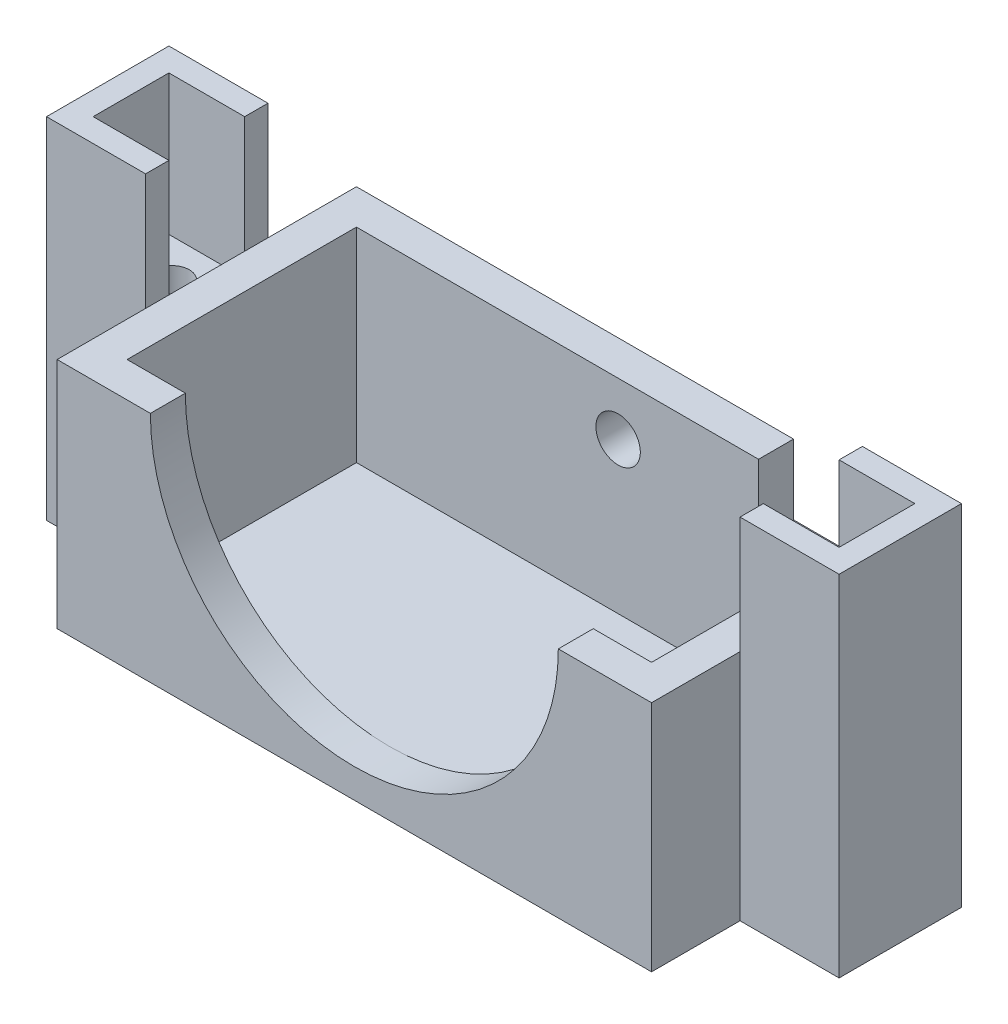
from build123d import *

# Parameters (mm, degrees)
SKETCH1_W           = 51
SKETCH1_H           = 25.68
BOSS_EXTRUDE1_DEPTH = 20
SKETCH2_W           = 45
SKETCH2_H           = 19.68
CUT_EXTRUDE1_DEPTH  = 17.5
CUT_EXTRUDE5_DEPTH  = 3
SKETCH10_R          = 1.905435321
SKETCH10_W          = 10
SKETCH10_H          = 6
CUT_EXTRUDE6_DEPTH  = 3
SKETCH11_W          = 6.5
SKETCH11_H          = 6.5
SKETCH11_R          = 1.5
BOSS_EXTRUDE4_DEPTH = 18
BOSS_EXTRUDE5_DEPTH = 30


with BuildPart() as part:
    # Sketch1 → Boss-Extrude1 (new body)
    with BuildSketch(Plane(origin=(0, 0, 0), x_dir=(1, 0, 0), z_dir=(0, 1, 0))):
        Rectangle(SKETCH1_W, SKETCH1_H)
    extrude(amount=BOSS_EXTRUDE1_DEPTH)

    # Sketch2 → Cut-Extrude1 (cut)
    with BuildSketch(Plane(origin=(0, 20, 0), x_dir=(1, 0, 0), z_dir=(0, 1, 0))):
        Rectangle(SKETCH2_W, SKETCH2_H)
    extrude(amount=-CUT_EXTRUDE1_DEPTH, mode=Mode.SUBTRACT)

    # Sketch9 → Cut-Extrude5 (cut)
    with BuildSketch(Plane.XY.offset(12.84)):
        with BuildLine():
            Line((-17.5, 20), (17.5, 20))
            ThreePointArc((17.5, 20), (0, 2.5), (-17.5, 20))
        make_face()
    extrude(amount=-CUT_EXTRUDE5_DEPTH, mode=Mode.SUBTRACT)

    # Sketch10 → Cut-Extrude6 (cut)
    with BuildSketch(Plane(origin=(0, 0, -12.84), x_dir=(-1, 0, 0), z_dir=(0, 0, -1))):
        with Locations((0.05, 15.45)):
            Circle(SKETCH10_R)
        with Locations((-17, 17)):
            Rectangle(SKETCH10_W, SKETCH10_H)
    extrude(amount=-CUT_EXTRUDE6_DEPTH, mode=Mode.SUBTRACT)

    # Sketch11 → Boss-Extrude4 (add)
    with BuildSketch(Plane.XZ):
        with Locations((-28.75, 0)):
            Rectangle(SKETCH11_W, SKETCH11_H)
        with Locations((-28.5, 0)):
            Circle(SKETCH11_R, mode=Mode.SUBTRACT)
        with Locations((28.75, 0)):
            Rectangle(SKETCH11_W, SKETCH11_H)
        with Locations((28.5, 0)):
            Circle(SKETCH11_R, mode=Mode.SUBTRACT)
    extrude(amount=-BOSS_EXTRUDE4_DEPTH)

    # Sketch12 → Boss-Extrude5 (add)
    with BuildSketch(Plane.XZ):
        Polygon((-25.5, -3.25), (-25.5, -5.25), (-34, -5.25), (-34, 5.25), (-25.5, 5.25), (-25.5, 3.25), (-32, 3.25), (-32, -3.25), align=None)
        Polygon((25.5, 3.25), (32, 3.25), (32, -3.25), (25.5, -3.25), (25.5, -5.25), (34, -5.25), (34, 5.25), (25.5, 5.25), align=None)
    extrude(amount=-BOSS_EXTRUDE5_DEPTH)


solid = part.part
